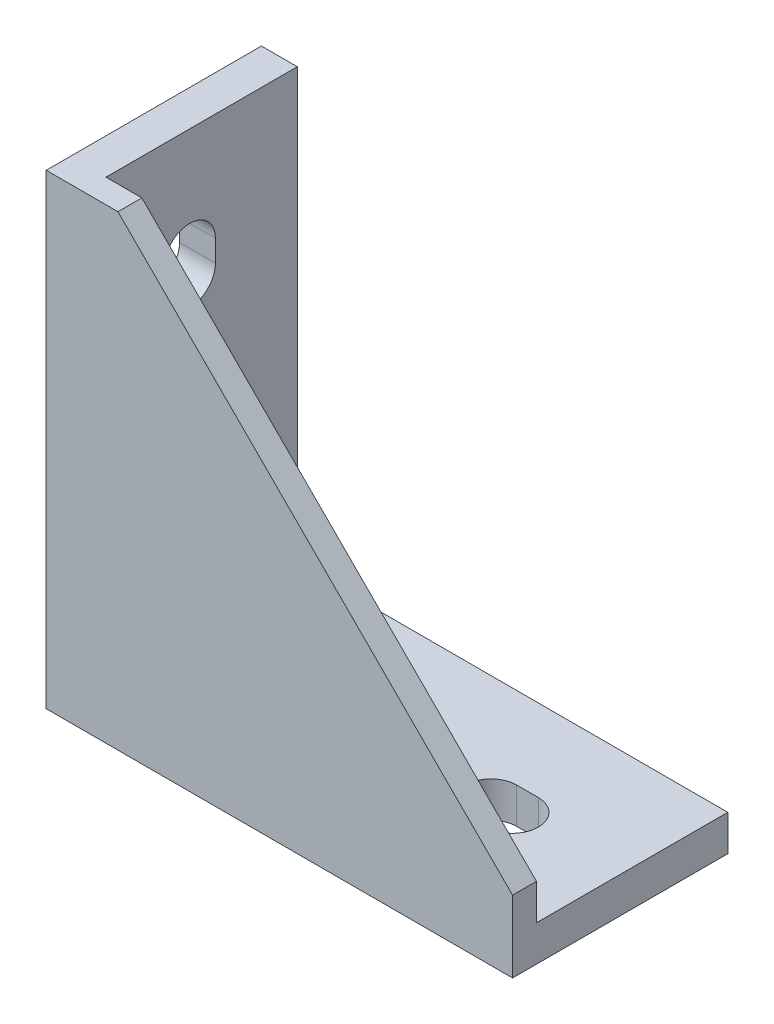
from build123d import *

# Parameters (mm, degrees)
EXTRUDE_1_DEPTH     = 18
EXTRUDE_2_DEPTH     = 4
CUT_EXTRUDE_1_DEPTH = 7
SKETCH_4_W          = 2.5
SKETCH_4_H          = 7.5
EXTRUDE_3_DEPTH     = 2.5


with BuildPart() as part:
    # Эскиз1 → Бобышка-Вытянуть1 (new body, symmetric)
    with BuildSketch(Plane.XY):
        Polygon((0, 78), (0, 0), (78, 0), (78, 6), (6, 6), (6, 78), align=None)
    extrude(amount=EXTRUDE_1_DEPTH, both=True)

    # Эскиз2 → Бобышка-Вытянуть2 (add)
    with BuildSketch(Plane.XY.offset(18)):
        Polygon((78, 6), (6, 6), (6, 78), (12, 78), (78, 12), align=None)
    extrude(amount=-EXTRUDE_2_DEPTH)

    # Эскиз3 → Вырез-Вытянуть1 (cut, through all)
    with BuildSketch(Plane(origin=(0, 6, 0), x_dir=(1, 0, 0), z_dir=(0, 1, 0))):
        with BuildLine():
            Line((18, 4.3), (31.4, 4.3))
            ThreePointArc((31.4, 4.3), (35.7, 0), (31.4, -4.3))
            Line((31.4, -4.3), (18, -4.3))
            ThreePointArc((18, -4.3), (13.7, 0), (18, 4.3))
        make_face()
        with BuildLine():
            Line((56.4, 4.3), (60, 4.3))
            ThreePointArc((60, 4.3), (64.3, 0), (60, -4.3))
            Line((60, -4.3), (56.4, -4.3))
            ThreePointArc((56.4, -4.3), (52.1, 0), (56.4, 4.3))
        make_face()
    cut_extrude_1 = extrude(amount=-CUT_EXTRUDE_1_DEPTH, mode=Mode.SUBTRACT)

    # Эскиз4 → Бобышка-Вытянуть3 (add)
    with BuildSketch(Plane.XZ):
        with Locations((4.25, 0)):
            Rectangle(SKETCH_4_W, SKETCH_4_H)
        with Locations((73.75, 0)):
            Rectangle(SKETCH_4_W, SKETCH_4_H)
    extrude_3 = extrude(amount=EXTRUDE_3_DEPTH)

    # Зеркальное отражение3: Вырез-Вытянуть1, Бобышка-Вытянуть3 across plane
    add(cut_extrude_1.mirror(Plane(origin=(0, 0, 0), x_dir=(0, 0, 1), z_dir=(-0.707106781, 0.707106781, 0))), mode=Mode.SUBTRACT)
    add(extrude_3.mirror(Plane(origin=(0, 0, 0), x_dir=(0, 0, 1), z_dir=(-0.707106781, 0.707106781, 0))))


solid = part.part
